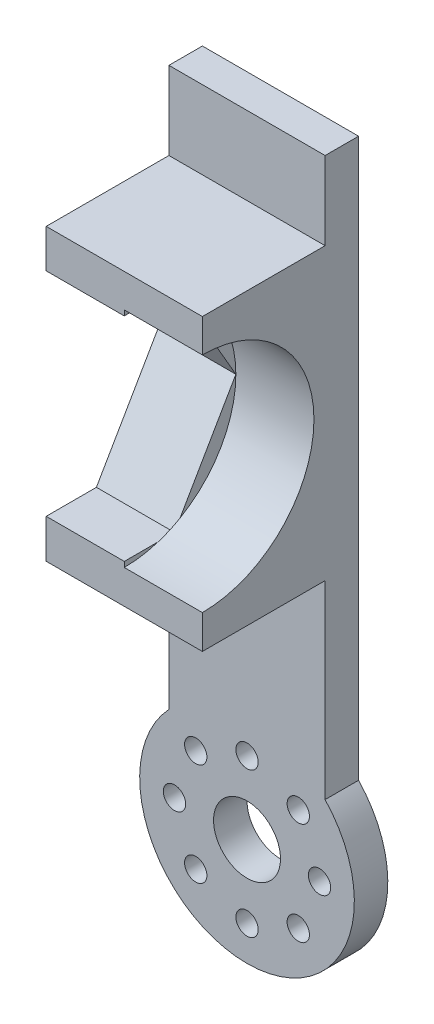
from build123d import *

# Parameters (mm, degrees)
SKETCH_1_W               = 14
SKETCH_1_H               = 13.200286042
EXTRUDE_1_DEPTH          = 3
SKETCH_3_OUTSIDE_W       = 35.048
SKETCH_3_OUTSIDE_H       = 82.027
CUT_EXTRUDE_2_DEPTH      = 3
SKETCH_4_R               = 3
CUT_EXTRUDE_3_DEPTH      = 10
SKETCH_5_R               = 1
CUT_EXTRUDE_4_DEPTH      = 10
SKETCH_6_W               = 4
SKETCH_6_H               = 4
EXTRUDE_3_DEPTH          = 3
CUT_EXTRUDE_5_DEPTH      = 10
PATTERN_CIRCULAR_1_COUNT = 8
SKETCH_9_W               = 14
SKETCH_9_H               = 26
EXTRUDE_4_DEPTH          = 11
CUT_EXTRUDE_8_DEPTH      = 7
SKETCH_11_R              = 10
CUT_EXTRUDE_9_DEPTH      = 7
SKETCH_12_W              = 4
SKETCH_12_H              = 4
CUT_EXTRUDE_10_DEPTH     = 1


with BuildPart() as part:
    # 草图1 → 凸台-拉伸1 (new body)
    with BuildSketch(Plane.XY):
        Rectangle(SKETCH_1_W, SKETCH_1_H)
        with BuildLine():
            ThreePointArc((-7, 6.600143021), (-9.620908892, 0), (-7, -6.600143021))
            Line((-7, -6.600143021), (-7, 6.600143021))
        make_face()
        with BuildLine():
            Line((7, -6.600143021), (-7, -6.600143021))
            ThreePointArc((-7, -6.600143021), (0, -9.620908892), (7, -6.600143021))
        make_face()
        with BuildLine():
            Line((7, 6.600143021), (7, -6.600143021))
            ThreePointArc((7, -6.600143021), (8.941707056, -3.550741166), (9.620908892, 0))
            ThreePointArc((9.620908892, 0), (8.941707056, 3.550741166), (7, 6.600143021))
        make_face()
        with BuildLine():
            ThreePointArc((7, 6.600143021), (0, 9.620908892), (-7, 6.600143021))
            Line((-7, 6.600143021), (7, 6.600143021))
        make_face()
        with BuildLine():
            Line((-7, 56.600143021), (-7, 6.600143021))
            ThreePointArc((-7, 6.600143021), (0, 9.620908892), (7, 6.600143021))
            Line((7, 6.600143021), (7, 56.600143021))
            Line((7, 56.600143021), (-7, 56.600143021))
        make_face()
    extrude(amount=EXTRUDE_1_DEPTH)

    # 草图3 outside → 切除-拉伸2 (cut)
    with BuildSketch(Plane.XY.offset(3)):
        with Locations((0, 23.4895)):
            Rectangle(SKETCH_3_OUTSIDE_W, SKETCH_3_OUTSIDE_H)
        with BuildLine():
            Line((7, 56.600143021), (0, 56.600143021))
            Line((0, 56.600143021), (-7, 56.600143021))
            Line((-7, 56.600143021), (-7, 6.600143021))
            ThreePointArc((-7, 6.600143021), (0, -9.620908892), (7, 6.600143021))
            Line((7, 6.600143021), (7, 56.600143021))
        make_face(mode=Mode.SUBTRACT)
        Polygon((-2, 28.600143021), (0, 28.600143021), (2, 28.600143021), (2, 24.600143021), (-2, 24.600143021), align=None)
        Polygon((-2, 38.600143021), (0, 38.600143021), (2, 38.600143021), (2, 34.600143021), (0, 34.600143021), (-2, 34.600143021), align=None)
        Polygon((-2, 48.600143021), (0, 48.600143021), (2, 48.600143021), (2, 44.600143021), (0, 44.600143021), (-2, 44.600143021), align=None)
    extrude(amount=-CUT_EXTRUDE_2_DEPTH, mode=Mode.SUBTRACT)

    # 草图4 → 切除-拉伸3 (cut)
    with BuildSketch(Plane.XY.offset(3)):
        Circle(SKETCH_4_R)
    extrude(amount=-CUT_EXTRUDE_3_DEPTH, mode=Mode.SUBTRACT)

    # 草图5 → 切除-拉伸4 (cut)
    with BuildSketch(Plane(origin=(0, 0, 0), x_dir=(-1, 0, 0), z_dir=(0, 0, -1))):
        with Locations((0, 6.5)):
            Circle(SKETCH_5_R)
    cut_extrude_4 = extrude(amount=-CUT_EXTRUDE_4_DEPTH, mode=Mode.SUBTRACT)

    # 草图6 → 凸台-拉伸3 (add)
    with BuildSketch(Plane(origin=(0, 0, 0), x_dir=(-1, 0, 0), z_dir=(0, 0, -1))):
        with Locations((0, 36.600143021)):
            Rectangle(SKETCH_6_W, SKETCH_6_H)
    extrude(amount=-EXTRUDE_3_DEPTH)

    # 草图7 → 切除-拉伸5 (cut)
    with BuildSketch(Plane(origin=(0, 0, 0), x_dir=(-1, 0, 0), z_dir=(0, 0, -1))):
        with BuildLine():
            ThreePointArc((0, 38.600143021), (-2, 36.600143021), (0, 34.600143021))
            Line((0, 34.600143021), (0, 38.600143021))
        make_face()
        with BuildLine():
            Line((0, 38.600143021), (0, 34.600143021))
            ThreePointArc((0, 34.600143021), (1.414213562, 35.185929459), (2, 36.600143021))
            ThreePointArc((2, 36.600143021), (1.414213562, 38.014356584), (0, 38.600143021))
        make_face()
    extrude(amount=-CUT_EXTRUDE_5_DEPTH, mode=Mode.SUBTRACT)

    # 阵列(圆周)1: 切除-拉伸4 ×8 about axis
    pattern_circular_1_axis = Axis((0, 0, 0), (0, 0, 1))
    for i in range(1, PATTERN_CIRCULAR_1_COUNT):
        add(cut_extrude_4.rotate(pattern_circular_1_axis, i * 360 / PATTERN_CIRCULAR_1_COUNT), mode=Mode.SUBTRACT)

    # 草图9 → 凸台-拉伸4 (add)
    with BuildSketch(Plane.XY.offset(3)):
        with Locations((0, 36.600143021)):
            Rectangle(SKETCH_9_W, SKETCH_9_H)
    extrude(amount=EXTRUDE_4_DEPTH)

    # 草图10 → 切除-拉伸8 (cut)
    with BuildSketch(Plane.ZY.offset(7)):
        Polygon((4, 36.618598328), (9.5, 27.092318886), (14, 27.092318886), (14, 46.14487777), (9.5, 46.14487777), align=None)
    extrude(amount=-CUT_EXTRUDE_8_DEPTH, mode=Mode.SUBTRACT)

    # 草图11 → 切除-拉伸9 (cut)
    with BuildSketch(Plane.ZY):
        with Locations((14, 36.618598328)):
            Circle(SKETCH_11_R)
    extrude(amount=-CUT_EXTRUDE_9_DEPTH, mode=Mode.SUBTRACT)

    # 草图12 → 切除-拉伸10 (cut)
    with BuildSketch(Plane(origin=(0, 0, 3), x_dir=(-1, 0, 0), z_dir=(0, 0, -1))):
        with Locations((0, 46.600143021)):
            Rectangle(SKETCH_12_W, SKETCH_12_H)
        with Locations((0, 26.600143021)):
            Rectangle(SKETCH_12_W, SKETCH_12_H)
    extrude(amount=-CUT_EXTRUDE_10_DEPTH, mode=Mode.SUBTRACT)


solid = part.part
